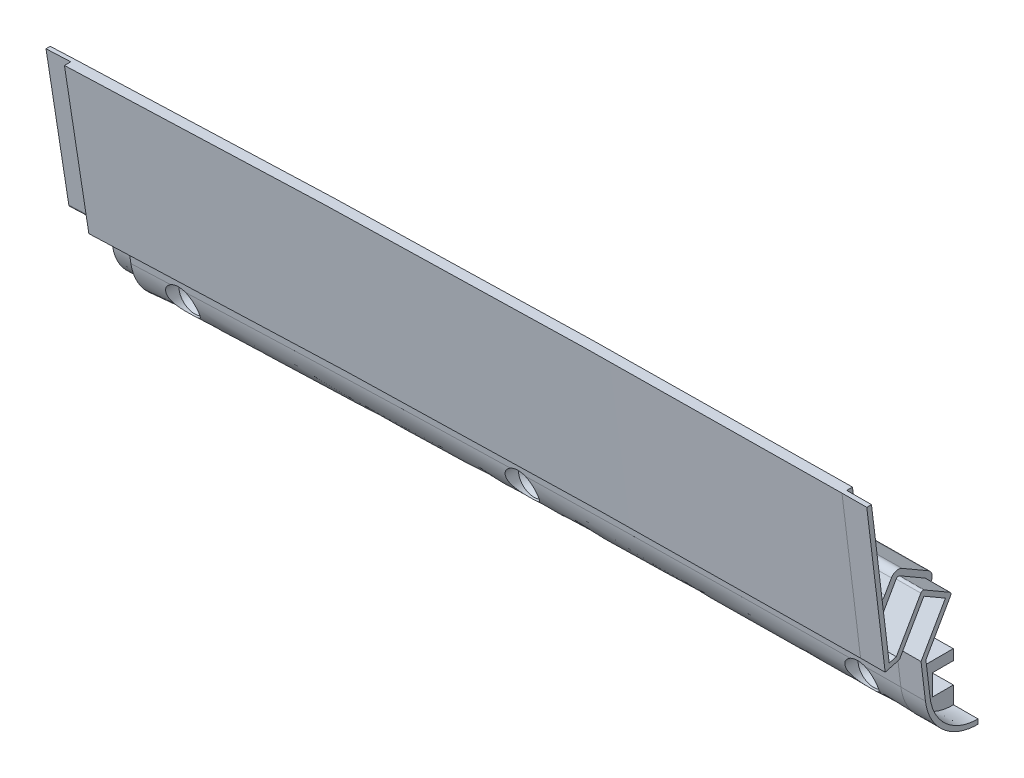
from build123d import *


with BuildPart() as part:
    # Sweep3: sweep along a path in Sketch3
    with BuildLine(Plane.XY.offset(101.6)) as sweep3_path:
        ThreePointArc((622.103936151, -83.199836272), (0, -43.636564626), (-622.103936151, -83.199836272))
    # Sketch4 → Sweep3 (sweep)
    with BuildSketch(Plane(origin=(-117.330566703, 4.430423936, 1117.6), x_dir=(0, 0, -1), z_dir=(0.9994536405585157, 0.03305178322465143, 0))):
        with BuildLine():
            Line((991.529482971, -5.453775083), (988.971801376, -5.453775083))
            Line((988.971801376, -5.453775083), (993.32506615, -42.283775083))
            Line((993.32506615, -42.283775083), (996.794703229, -41.354088728))
            Line((996.794703229, -41.354088728), (1002.763703229, -31.015013775))
            Line((1002.763703229, -31.015013775), (1007.999, -34.037749136))
            Line((1007.999, -34.037749136), (1002.03, -44.376824659))
            Line((1002.03, -44.376824659), (1003.077032208, -53.235049058))
            ThreePointArc((1003.077032208, -53.235049058), (1007.29752688, -61.276835992), (1015.8095, -64.443731312))
            Line((1015.8095, -64.443731312), (1015.8095, -59.12218153))
            Line((1015.8095, -59.12218153), (1010.7295, -59.12218153))
            Line((1010.7295, -59.12218153), (1010.7295, -54.041969025))
            Line((1010.7295, -54.041969025), (1015.8095, -54.041969025))
            Line((1015.8095, -54.041969025), (1015.8095, -51.501969025))
            Line((1015.8095, -51.501969025), (1007.687322123, -51.501969025))
            ThreePointArc((1007.687322123, -51.501969025), (1005.99997215, -50.860507955), (1005.164881483, -49.260118685))
            Line((1005.164881483, -49.260118685), (1004.750455768, -45.75394576))
            ThreePointArc((1004.750455768, -45.75394576), (1004.7850335, -44.943801809), (1005.073167189, -44.18583887))
            Line((1005.073167189, -44.18583887), (1010.516206197, -34.757795418))
            ThreePointArc((1010.516206197, -34.757795418), (1010.706497969, -33.312277166), (1009.818941274, -32.155567572))
            Line((1009.818941274, -32.155567572), (1003.483804566, -28.49781089))
            ThreePointArc((1003.483804566, -28.49781089), (1002.038222268, -28.307482122), (1000.881475684, -29.195102853))
            Line((1000.881475684, -29.195102853), (999.272416391, -31.982200293))
            ThreePointArc((999.272416391, -31.982200293), (996.560692883, -33.200105913), (994.550246564, -31.010392672))
            Line((994.550246564, -31.010392672), (991.529482971, -5.453775083))
        make_face()
    sweep(path=sweep3_path.line)

    # SurfaceCut1
    split(bisect_by=Plane(origin=(-211.442164364, -9.040193423, 0), x_dir=(0.04271589869142412, -0.9990872594518379, 0), z_dir=(-0.9990872594518379, -0.04271589869142412, 0)), keep=Keep.BOTTOM)

    # SurfaceCut2
    split(bisect_by=Plane(origin=(-22.670567211, -0.103737371, 0), x_dir=(-0.004575813400742646, 0.9999895309110599, 0), z_dir=(0.99998953091106, 0.004575813400742646, 0)), keep=Keep.BOTTOM)

    # Sketch8 → Cut-Revolve1 (revolve, cut)
    with BuildSketch(Plane(origin=(-117.056038996, -3.871025798, 0), x_dir=(0, 0, -1), z_dir=(0.9994536405585157, 0.03305178322465143, 0)), mode=Mode.PRIVATE) as cut_revolve1_sk:
        Polygon((-119.5705, -48.27608749), (-106.8705, -48.27608749), (-106.8705, -46.37108749), (-108.7755, -46.37108749), (-110.6805, -44.46608749), (-119.5705, -44.46608749), align=None)
    cut_revolve1 = revolve(cut_revolve1_sk.sketch.rotate(Axis((-115.460428217, -52.120737191, 119.5705), (0, 0, -1)), 91.894072645), axis=Axis((-115.460428217, -52.120737191, 119.5705), (0, 0, -1)), mode=Mode.SUBTRACT)

    # Sketch-Pattern1: Cut-Revolve1 at 2 more places
    with Locations((82.543476, 1.248991, 0), (-82.510753, -2.638363, 0)):
        add(cut_revolve1, mode=Mode.SUBTRACT)

    # Sweep4: sweep along a path in Sketch12
    with BuildLine(Plane(origin=(0, 0, 101.7905), x_dir=(-1, 0, 0), z_dir=(0, 0, -1))) as sweep4_path:
        ThreePointArc((22.461775047, -45.732778631), (19.477278647, -45.720029285), (16.492775047, -45.709094497))
    # Sketch11 → Sweep4 (sweep)
    with BuildSketch(Plane(origin=(-22.670567211, -0.103737371, 0), x_dir=(0, 0, -1), z_dir=(0.9999895309110599, 0.004575813400742645, 0))):
        with BuildLine():
            Line((-127.477241199, 0.416616241), (-123.294888708, -34.965832659))
            Line((-123.294888708, -34.965832659), (-121.558436986, -34.500572786))
            Line((-121.558436986, -34.500572786), (-115.572163807, -24.132043494))
            ThreePointArc((-115.572163807, -24.132043494), (-115.18658777, -23.836180594), (-114.704737676, -23.899617362))
            Line((-114.704737676, -23.899617362), (-108.589559095, -27.430217362))
            ThreePointArc((-108.589559095, -27.430217362), (-108.293696195, -27.8157934), (-108.357132963, -28.297643494))
            Line((-108.357132963, -28.297643494), (-114.390345193, -38.747473608))
            Line((-114.390345193, -38.747473608), (-113.38787021, -47.228347431))
            add(Edge.make_bspline(
                [(-113.38787021, -47.228347431), (-113.304795542, -47.931153716), (-113.005394664, -49.331088938), (-111.931567303, -51.921905104), (-109.715936846, -54.745328052), (-106.035083238, -56.946179963), (-103.201893406, -57.44100982), (-101.801323322, -57.427746915)],
                knots=[0, 0, 0, 0, 0.125, 0.25, 0.5, 0.75, 1, 1, 1, 1], degree=3))
            Line((-101.801323322, -57.427746915), (-101.7905, -57.427746915))
            Line((-101.7905, -57.427746915), (-101.7905, -58.570695669))
            add(Edge.make_bspline(
                [(-114.522967792, -47.362520754), (-114.477136038, -47.750254403), (-114.413580033, -48.134868747), (-114.251122313, -48.897876915), (-114.152305696, -49.275250489), (-113.807619255, -50.383084428), (-113.512952594, -51.094253598), (-112.794349261, -52.462021573), (-112.366195112, -53.121992394), (-111.411403795, -54.334514945), (-110.882225451, -54.893793968), (-110.009875034, -55.661414508), (-109.70425095, -55.906443165), (-109.076570448, -56.363840109), (-108.75418736, -56.576773283), (-107.762018779, -57.169401136), (-107.067422067, -57.503308187), (-105.974437358, -57.909885857), (-105.601773783, -58.029259911), (-104.85459633, -58.231444087), (-104.478193263, -58.315009286), (-103.340677537, -58.513974287), (-102.571330027, -58.578089855), (-101.7905, -58.570695669)],
                knots=[0, 0, 0, 0, 0.0625, 0.0625, 0.125, 0.125, 0.25, 0.25, 0.375, 0.375, 0.5, 0.5, 0.5625, 0.5625, 0.625, 0.625, 0.75, 0.75, 0.8125, 0.8125, 0.875, 0.875, 1, 1, 1, 1], degree=3))
            Line((-114.522967792, -47.362520754), (-115.57, -38.504695669))
            Line((-115.57, -38.504695669), (-109.601, -28.166084399))
            Line((-109.601, -28.166084399), (-114.836296771, -25.143484399))
            Line((-114.836296771, -25.143484399), (-120.805296771, -35.482095669))
            Line((-120.805296771, -35.482095669), (-124.27493385, -36.411740234))
            Line((-124.27493385, -36.411740234), (-128.628198624, 0.416616241))
            Line((-128.628198624, 0.416616241), (-127.477241199, 0.416616241))
        make_face()
    sweep(path=sweep4_path.line)

    # Sweep5: sweep along a path in Sketch16
    with BuildLine(Plane(origin=(0, 0, 101.7905), x_dir=(-1, 0, 0), z_dir=(0, 0, -1))) as sweep5_path:
        ThreePointArc((215.647406705, -50.42045008), (212.665748146, -50.290245196), (209.684010975, -50.161853153))
    # Sketch15 → Sweep5 (sweep)
    with BuildSketch(Plane(origin=(-211.442164364, -9.040193423, 0), x_dir=(0, 0, 1), z_dir=(-0.9990872594518379, -0.04271589869142412, 0))):
        with BuildLine():
            Line((113.00950435, -42.713331456), (113.97237291, -34.567525415))
            ThreePointArc((113.97237291, -34.567525415), (113.963727961, -34.364981701), (113.891689273, -34.175484686))
            Line((113.891689273, -34.175484686), (107.519177285, -23.137970149))
            Line((107.519177285, -23.137970149), (115.394119486, -18.591370149))
            Line((115.394119486, -18.591370149), (121.677968823, -29.475316467))
            ThreePointArc((121.677968823, -29.475316467), (121.841334284, -29.661598015), (122.06355177, -29.771181218))
            Line((122.06355177, -29.771181218), (122.259394286, -29.823654698))
            ThreePointArc((122.259394286, -29.823654698), (122.780015415, -29.735923875), (123.054347243, -29.284830643))
            Line((123.054347243, -29.284830643), (127.093588723, 4.886907775))
            Line((127.093588723, 4.886907775), (126.070517029, 4.886907775))
            Line((126.070517029, 4.886907775), (123.049753436, -20.668571968))
            add(Edge.make_bspline(
                [(123.049753436, -20.668571968), (123.018406598, -20.933764287), (122.944898871, -21.192703381), (122.72486191, -21.671025374), (122.574983618, -21.89613649), (122.218479429, -22.283693321), (122.006878086, -22.451668909), (121.662818096, -22.646204147), (121.543504304, -22.701961436), (121.295473201, -22.795007288), (121.166493424, -22.832124521), (120.907997451, -22.885096572), (120.777385583, -22.901432856), (120.51342226, -22.913717924), (120.37910716, -22.909438417), (120.116311005, -22.880334184), (119.986998098, -22.855691982), (119.732512188, -22.786374688), (119.606266969, -22.741161694), (119.243601748, -22.578043456), (119.021351761, -22.432970621), (118.626712377, -22.076251458), (118.461102845, -21.871598209), (118.327583609, -21.640336089)],
                knots=[0, 0, 0, 0, 0.125, 0.125, 0.25, 0.25, 0.375, 0.375, 0.4375, 0.4375, 0.5, 0.5, 0.5625, 0.5625, 0.625, 0.625, 0.6875, 0.6875, 0.75, 0.75, 0.875, 0.875, 1, 1, 1, 1], degree=3))
            Line((118.327583609, -21.640336089), (116.718524316, -18.853363359))
            ThreePointArc((116.718524316, -18.853363359), (115.561765682, -17.965779092), (114.116195434, -18.156102576))
            Line((114.116195434, -18.156102576), (107.781058726, -21.813695606))
            ThreePointArc((107.781058726, -21.813695606), (106.893505265, -22.97034131), (107.083793803, -24.415806877))
            Line((107.083793803, -24.415806877), (112.526832811, -33.84342694))
            ThreePointArc((112.526832811, -33.84342694), (112.814966033, -34.601353512), (112.849544232, -35.411463252))
            Line((112.849544232, -35.411463252), (112.435118517, -38.917478209))
            ThreePointArc((112.435118517, -38.917478209), (111.600006373, -40.51781438), (109.912677877, -41.159227425))
            Line((109.912677877, -41.159227425), (101.7905, -41.159227425))
            Line((101.7905, -41.159227425), (101.7905, -43.699112741))
            Line((101.7905, -43.699112741), (106.8705, -43.699112741))
            Line((106.8705, -43.699112741), (106.8705, -48.779095512))
            Line((106.8705, -48.779095512), (101.7905, -48.779095512))
            Line((101.7905, -48.779095512), (101.7905, -52.576472462))
            Line((101.7905, -52.576472462), (101.804931097, -52.576472462))
            add(Edge.make_bspline(
                [(101.804931097, -52.576472462), (102.489279498, -52.582953001), (103.868868527, -52.467414443), (106.485766193, -51.75509811), (109.465837716, -49.976138537), (112.028433947, -46.715360308), (112.850511097, -44.058404026), (113.00950435, -42.713331456)],
                knots=[0, 0, 0, 0, 0.125, 0.25, 0.5, 0.75, 1, 1, 1, 1], degree=3))
        make_face()
    sweep(path=sweep5_path.line)


solid = part.part
